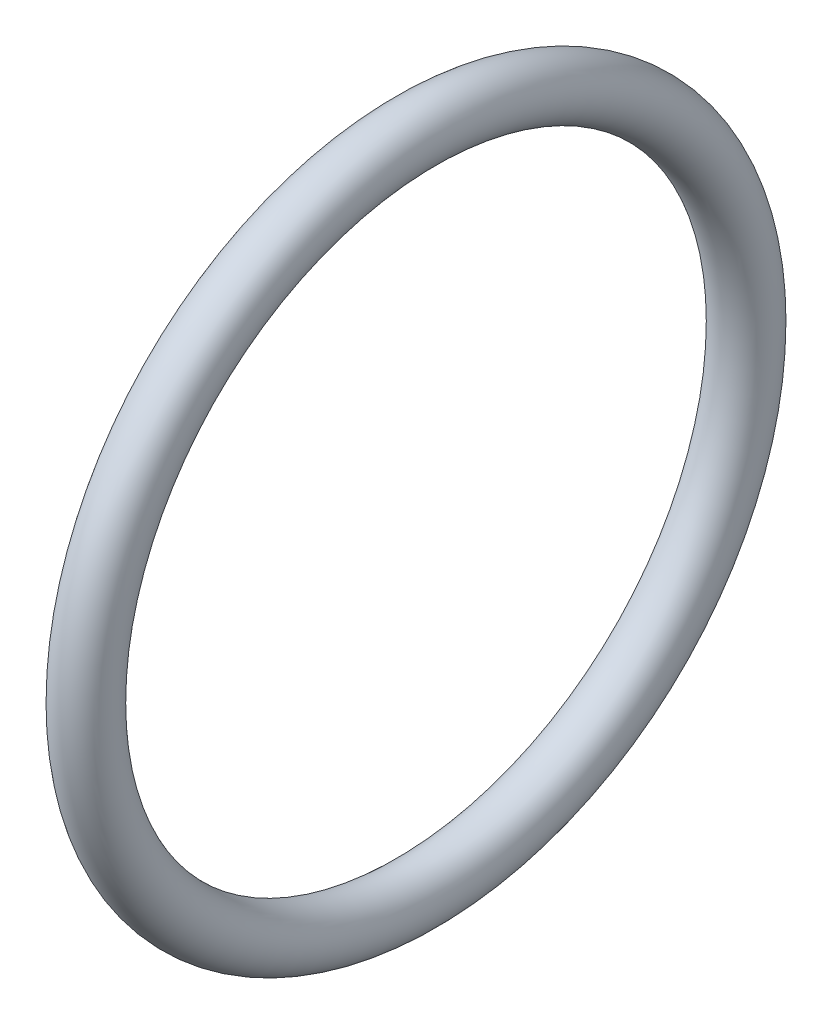
from build123d import *

# Parameters (mm, degrees)
SKETCH3_R = 0.699999997


with BuildPart() as part:
    # Sketch3 → Revolve1 (revolve)
    with BuildSketch(Plane.XY):
        with Locations((17.339799839, 8.199999983)):
            Circle(SKETCH3_R)
    revolve(axis=Axis((0, 0, 0), (1, 0, 0)))


solid = part.part
